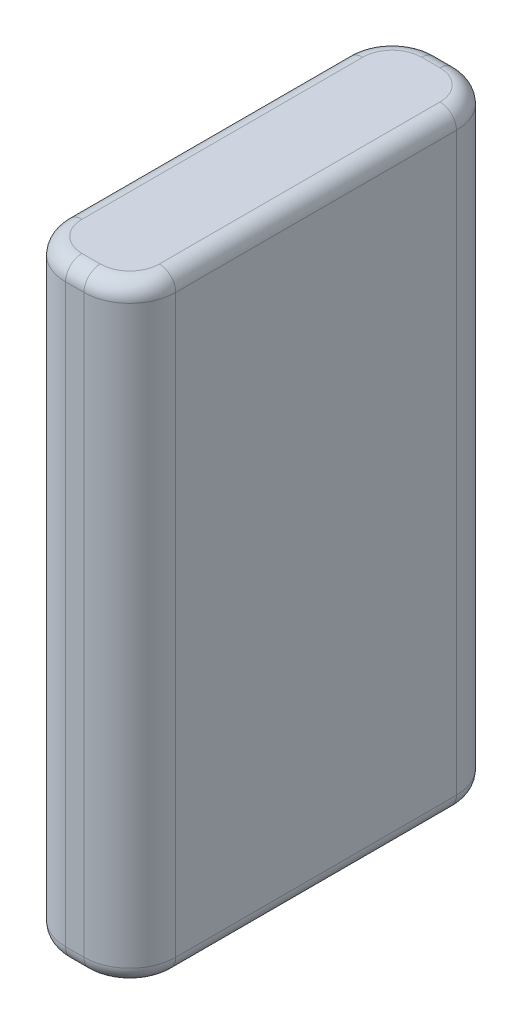
from build123d import *

# Parameters (mm, degrees)
SKETCH1_W           = 8.4
SKETCH1_H           = 28.4
BOSS_EXTRUDE1_DEPTH = 46.4
FILLET1_R           = 3.5
FILLET2_R           = 1.25


with BuildPart() as part:
    # Sketch1 → Boss-Extrude1 (new body)
    with BuildSketch(Plane(origin=(0, 0, 0), x_dir=(1, 0, 0), z_dir=(0, 1, 0))):
        Rectangle(SKETCH1_W, SKETCH1_H)
    extrude(amount=BOSS_EXTRUDE1_DEPTH)

    # Fillet1
    fillet1_edges = [part.edges().sort_by_distance(p)[0] for p in [
        (4.2, 23.2, 14.2),
        (-4.2, 23.2, 14.2),
        (-4.2, 23.2, -14.2),
        (4.2, 23.2, -14.2),
    ]]
    fillet(fillet1_edges, radius=FILLET1_R)

    # Fillet2
    fillet2_edges = [part.edges().sort_by_distance(p)[0] for p in [
        (-4.2, 0, 0),
        (-4.2, 46.4, 0),
        (4.2, 0, 0),
        (0, 0, 14.2),
        (0, 0, -14.2),
        (-3.174873734, 0, 13.174873734),
        (3.174873734, 0, 13.174873734),
        (3.174873734, 0, -13.174873734),
        (-3.174873734, 0, -13.174873734),
        (0, 46.4, -14.2),
        (4.2, 46.4, 0),
        (0, 46.4, 14.2),
        (-3.174873734, 46.4, 13.174873734),
        (3.174873734, 46.4, 13.174873734),
        (3.174873734, 46.4, -13.174873734),
        (-3.174873734, 46.4, -13.174873734),
    ]]
    fillet(fillet2_edges, radius=FILLET2_R)


solid = part.part
